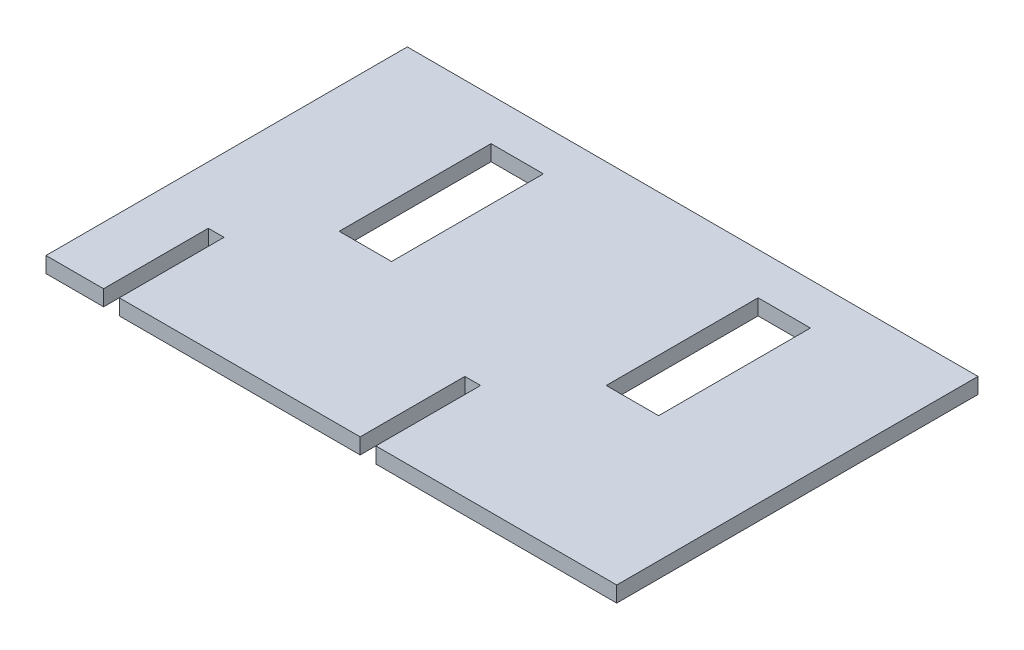
from build123d import *

# Parameters (mm, degrees)
SKETCH1_W           = 54.5
SKETCH1_H           = 34.5
BOSS_EXTRUDE1_DEPTH = 1.5
SKETCH6_W           = 5
SKETCH6_H           = 14.5
CUT_EXTRUDE1_DEPTH  = 2
SKETCH9_W           = 5
SKETCH9_H           = 14.5
CUT_EXTRUDE2_DEPTH  = 2
SKETCH27_W          = 1.5
SKETCH27_H          = 10
CUT_EXTRUDE3_DEPTH  = 2
SKETCH37_W          = 1.5
SKETCH37_H          = 10
CUT_EXTRUDE10_DEPTH = 2


with BuildPart() as part:
    # Sketch1 → Boss-Extrude1 (new body)
    with BuildSketch(Plane(origin=(0, 0, 0), x_dir=(1, 0, 0), z_dir=(0, 1, 0))):
        Rectangle(SKETCH1_W, SKETCH1_H)
    extrude(amount=BOSS_EXTRUDE1_DEPTH)

    # Sketch6 → Cut-Extrude1 (cut)
    with BuildSketch(Plane(origin=(0, 1.5, 0), x_dir=(1, 0, 0), z_dir=(0, 1, 0))):
        with Locations((-12.75, 6)):
            Rectangle(SKETCH6_W, SKETCH6_H)
    extrude(amount=-CUT_EXTRUDE1_DEPTH, mode=Mode.SUBTRACT)

    # Sketch9 → Cut-Extrude2 (cut)
    with BuildSketch(Plane(origin=(0, 1.5, 0), x_dir=(1, 0, 0), z_dir=(0, 1, 0))):
        with Locations((12.75, 6)):
            Rectangle(SKETCH9_W, SKETCH9_H)
    extrude(amount=-CUT_EXTRUDE2_DEPTH, mode=Mode.SUBTRACT)

    # Sketch27 → Cut-Extrude3 (cut)
    with BuildSketch(Plane(origin=(0, 1.5, 0), x_dir=(1, 0, 0), z_dir=(0, 1, 0))):
        with Locations((-21, -12.25)):
            Rectangle(SKETCH27_W, SKETCH27_H)
    extrude(amount=-CUT_EXTRUDE3_DEPTH, mode=Mode.SUBTRACT)

    # Sketch37 → Cut-Extrude10 (cut)
    with BuildSketch(Plane(origin=(0, 1.5, 0), x_dir=(1, 0, 0), z_dir=(0, 1, 0))):
        with Locations((3.5, -12.25)):
            Rectangle(SKETCH37_W, SKETCH37_H)
    extrude(amount=-CUT_EXTRUDE10_DEPTH, mode=Mode.SUBTRACT)


solid = part.part
